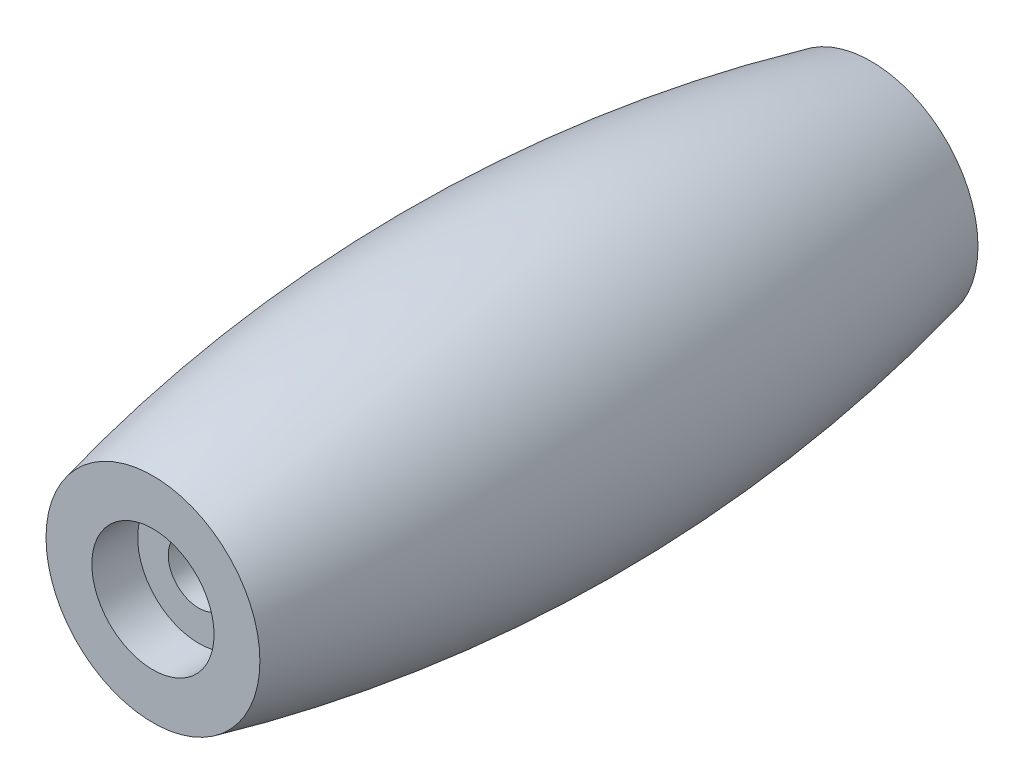
from build123d import *

# Parameters (mm, degrees)
SKETCH_2_R               = 2
CUT_EXTRUDE_1_DEPTH      = 1.0000001
CUT_EXTRUDE_1_DEPTH_BACK = 48.0000001
SKETCH_3_R               = 4
CUT_EXTRUDE_2_DEPTH      = 3


with BuildPart() as part:
    # Эскиз1 → Повернуть1 (revolve)
    with BuildSketch(Plane(origin=(0, 0, 0), x_dir=(1, 0, 0), z_dir=(0, 1, 0))):
        with BuildLine():
            Line((0, 0), (0, 47))
            Line((0, 47), (-7, 47))
            ThreePointArc((-7, 47), (-9.725, 23.5), (-7, 0))
            Line((-7, 0), (0, 0))
        make_face()
    revolve(axis=Axis((0, 0, 0), (0, 0, -1)))

    # Эскиз2 → Вырез-Вытянуть1 (cut, two sides)
    with BuildSketch(Plane.XY) as cut_extrude_1_sk:
        Circle(SKETCH_2_R)
    extrude(amount=CUT_EXTRUDE_1_DEPTH, mode=Mode.SUBTRACT)
    extrude(cut_extrude_1_sk.sketch, amount=-CUT_EXTRUDE_1_DEPTH_BACK, mode=Mode.SUBTRACT)

    # Эскиз3 → Вырез-Вытянуть2 (cut)
    with BuildSketch(Plane.XY):
        Circle(SKETCH_3_R)
    cut_extrude_2 = extrude(amount=-CUT_EXTRUDE_2_DEPTH, mode=Mode.SUBTRACT)

    # Зеркальное отражение1: Вырез-Вытянуть2 across plane
    add(cut_extrude_2.mirror(Plane.XY.offset(-23.5)), mode=Mode.SUBTRACT)


solid = part.part
